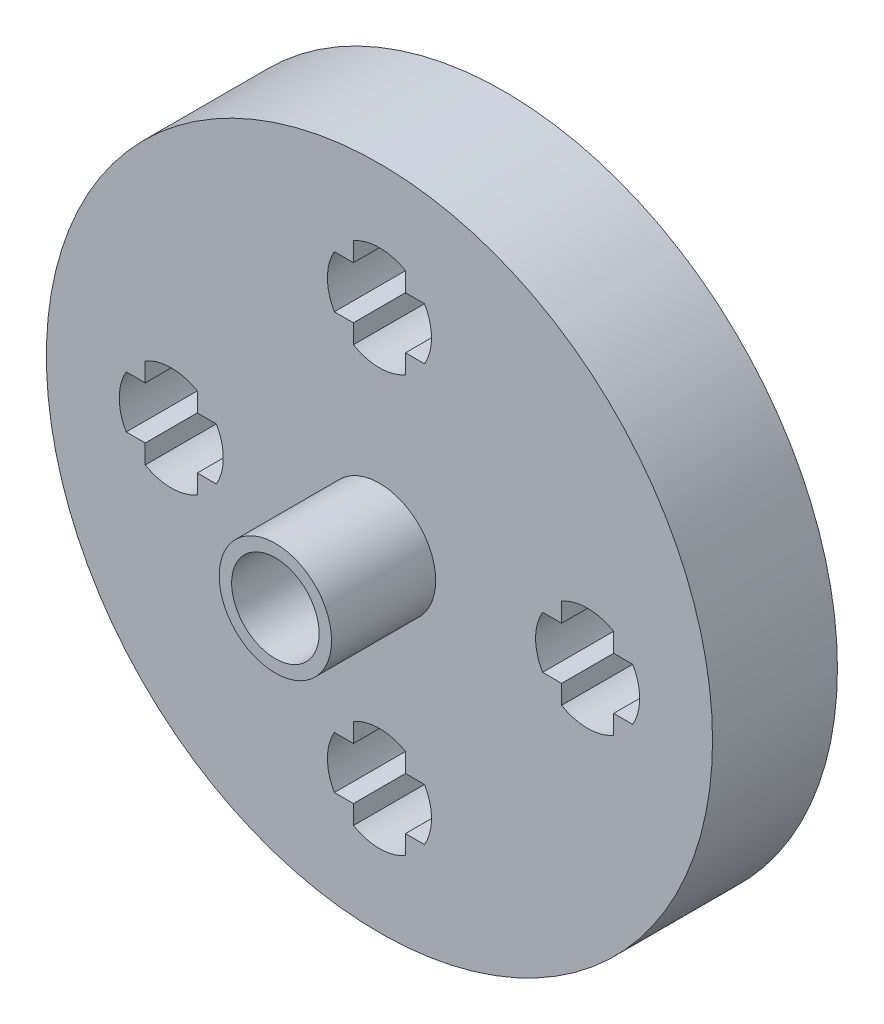
from build123d import *

# Parameters (mm, degrees)
CROQUIS1_R              = 16
SALIENTE_EXTRUIR1_DEPTH = 6
CROQUIS2_R              = 2.7
CROQUIS2_R_2            = 2.1
SALIENTE_EXTRUIR2_DEPTH = 5


with BuildPart() as part:
    # Croquis1 → Saliente-Extruir1 (new body)
    with BuildSketch(Plane.XY):
        Circle(CROQUIS1_R)
        with BuildLine():
            Line((2.165063509, 11.25), (1.25, 11.25))
            Line((1.25, 11.25), (1.25, 12.165063509))
            ThreePointArc((1.25, 12.165063509), (0.647047613, 12.414814566), (0, 12.5))
            ThreePointArc((0, 12.5), (-0.647047613, 12.414814566), (-1.25, 12.165063509))
            Line((-1.25, 12.165063509), (-1.25, 11.25))
            Line((-1.25, 11.25), (-2.165063509, 11.25))
            ThreePointArc((-2.165063509, 11.25), (-2.414814566, 10.647047613), (-2.5, 10))
            ThreePointArc((-2.5, 10), (-2.414814566, 9.352952387), (-2.165063509, 8.75))
            Line((-2.165063509, 8.75), (-1.25, 8.75))
            Line((-1.25, 8.75), (-1.25, 7.834936491))
            ThreePointArc((-1.25, 7.834936491), (-0.647047613, 7.585185434), (0, 7.5))
            ThreePointArc((0, 7.5), (0.647047613, 7.585185434), (1.25, 7.834936491))
            Line((1.25, 7.834936491), (1.25, 8.75))
            Line((1.25, 8.75), (2.165063509, 8.75))
            ThreePointArc((2.165063509, 8.75), (2.414814566, 9.352952387), (2.5, 10))
            ThreePointArc((2.5, 10), (2.414814566, 10.647047613), (2.165063509, 11.25))
        make_face(mode=Mode.SUBTRACT)
        with BuildLine():
            Line((11.25, -1.25), (12.165063509, -1.25))
            ThreePointArc((12.165063509, -1.25), (12.414814566, -0.647047613), (12.5, 0))
            ThreePointArc((12.5, 0), (12.414814566, 0.647047613), (12.165063509, 1.25))
            Line((12.165063509, 1.25), (11.25, 1.25))
            Line((11.25, 1.25), (11.25, 2.165063509))
            ThreePointArc((11.25, 2.165063509), (10.647047613, 2.414814566), (10, 2.5))
            ThreePointArc((10, 2.5), (9.352952387, 2.414814566), (8.75, 2.165063509))
            Line((8.75, 2.165063509), (8.75, 1.25))
            Line((8.75, 1.25), (7.834936491, 1.25))
            ThreePointArc((7.834936491, 1.25), (7.585185434, 0.647047613), (7.5, 0))
            ThreePointArc((7.5, 0), (7.585185434, -0.647047613), (7.834936491, -1.25))
            Line((7.834936491, -1.25), (8.75, -1.25))
            Line((8.75, -1.25), (8.75, -2.165063509))
            ThreePointArc((8.75, -2.165063509), (9.352952387, -2.414814566), (10, -2.5))
            ThreePointArc((10, -2.5), (10.647047613, -2.414814566), (11.25, -2.165063509))
            Line((11.25, -2.165063509), (11.25, -1.25))
        make_face(mode=Mode.SUBTRACT)
        with BuildLine():
            Line((-1.25, -11.25), (-1.25, -12.165063509))
            ThreePointArc((-1.25, -12.165063509), (-0.647047613, -12.414814566), (0, -12.5))
            ThreePointArc((0, -12.5), (0.647047613, -12.414814566), (1.25, -12.165063509))
            Line((1.25, -12.165063509), (1.25, -11.25))
            Line((1.25, -11.25), (2.165063509, -11.25))
            ThreePointArc((2.165063509, -11.25), (2.414814566, -10.647047613), (2.5, -10))
            ThreePointArc((2.5, -10), (2.414814566, -9.352952387), (2.165063509, -8.75))
            Line((2.165063509, -8.75), (1.25, -8.75))
            Line((1.25, -8.75), (1.25, -7.834936491))
            ThreePointArc((1.25, -7.834936491), (0.647047613, -7.585185434), (0, -7.5))
            ThreePointArc((0, -7.5), (-0.647047613, -7.585185434), (-1.25, -7.834936491))
            Line((-1.25, -7.834936491), (-1.25, -8.75))
            Line((-1.25, -8.75), (-2.165063509, -8.75))
            ThreePointArc((-2.165063509, -8.75), (-2.414814566, -9.352952387), (-2.5, -10))
            ThreePointArc((-2.5, -10), (-2.414814566, -10.647047613), (-2.165063509, -11.25))
            Line((-2.165063509, -11.25), (-1.25, -11.25))
        make_face(mode=Mode.SUBTRACT)
        with BuildLine():
            Line((-11.25, 1.25), (-12.165063509, 1.25))
            ThreePointArc((-12.165063509, 1.25), (-12.414814566, 0.647047613), (-12.5, 0))
            ThreePointArc((-12.5, 0), (-12.414814566, -0.647047613), (-12.165063509, -1.25))
            Line((-12.165063509, -1.25), (-11.25, -1.25))
            Line((-11.25, -1.25), (-11.25, -2.165063509))
            ThreePointArc((-11.25, -2.165063509), (-10.647047613, -2.414814566), (-10, -2.5))
            ThreePointArc((-10, -2.5), (-9.352952387, -2.414814566), (-8.75, -2.165063509))
            Line((-8.75, -2.165063509), (-8.75, -1.25))
            Line((-8.75, -1.25), (-7.834936491, -1.25))
            ThreePointArc((-7.834936491, -1.25), (-7.585185434, -0.647047613), (-7.5, 0))
            ThreePointArc((-7.5, 0), (-7.585185434, 0.647047613), (-7.834936491, 1.25))
            Line((-7.834936491, 1.25), (-8.75, 1.25))
            Line((-8.75, 1.25), (-8.75, 2.165063509))
            ThreePointArc((-8.75, 2.165063509), (-9.352952387, 2.414814566), (-10, 2.5))
            ThreePointArc((-10, 2.5), (-10.647047613, 2.414814566), (-11.25, 2.165063509))
            Line((-11.25, 2.165063509), (-11.25, 1.25))
        make_face(mode=Mode.SUBTRACT)
    extrude(amount=SALIENTE_EXTRUIR1_DEPTH)

    # Croquis2 → Saliente-Extruir2 (add)
    with BuildSketch(Plane.XY.offset(6)):
        Circle(CROQUIS2_R)
        Circle(CROQUIS2_R_2, mode=Mode.SUBTRACT)
    extrude(amount=SALIENTE_EXTRUIR2_DEPTH)


solid = part.part
